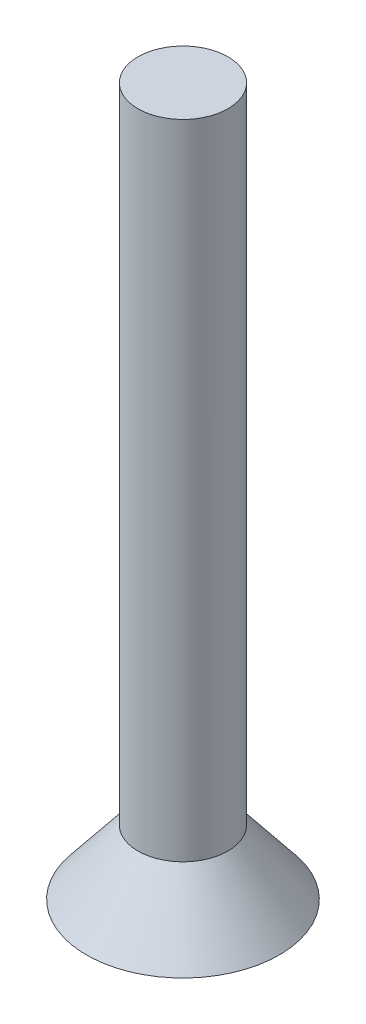
from build123d import *

# Parameters (mm, degrees)
SKETCH_3_R          = 0.7
EXTRUDE_1_DEPTH     = 10
CUT_EXTRUDE_1_DEPTH = 0.3


with BuildPart() as part:
    # 草图2 → 旋转1 (revolve)
    with BuildSketch(Plane.XY):
        Polygon((0, 0), (1.5, 0), (0.7, 1), (0, 1), align=None)
    revolve(axis=Axis((0, 0, 0), (0, 1, 0)))

    # 草图3 → 凸台-拉伸1 (add)
    with BuildSketch(Plane(origin=(0, 1, 0), x_dir=(1, 0, 0), z_dir=(0, 1, 0))):
        Circle(SKETCH_3_R)
    extrude(amount=EXTRUDE_1_DEPTH)

    # 草图4 → 切除-拉伸1 (cut)
    with BuildSketch(Plane.XZ):
        Polygon((0.25, -0.25), (0.25, -0.765105953), (0, -0.765105953), (-0.25, -0.765105953), (-0.25, -0.25), (-0.765105953, -0.25), (-0.765105953, 0), (-0.765105953, 0.25), (-0.25, 0.25), (-0.25, 0.765105953), (0, 0.765105953), (0.25, 0.765105953), (0.25, 0.25), (0.765105953, 0.25), (0.765105953, 0), (0.765105953, -0.25), align=None)
    extrude(amount=-CUT_EXTRUDE_1_DEPTH, mode=Mode.SUBTRACT)


solid = part.part
